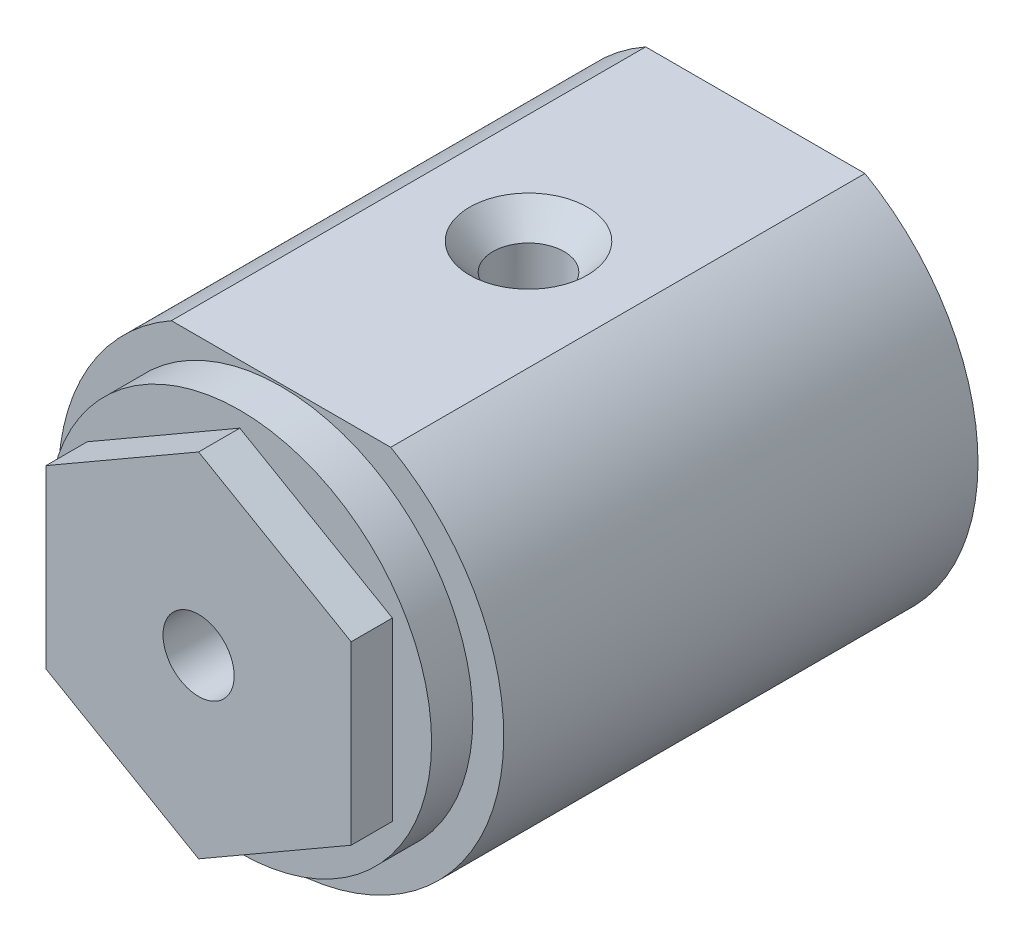
from build123d import *

# Parameters (mm, degrees)
BOSS_EXTRUDE1_DEPTH                            = 23
CSK_FOR_4_FLAT_HEAD_MACHINE_SCREW1_D           = 3.4544
CSK_FOR_4_FLAT_HEAD_MACHINE_SCREW1_DEPTH       = 3.5
CSK_FOR_4_FLAT_HEAD_MACHINE_SCREW1_CSINK_D     = 5.715
CSK_FOR_4_FLAT_HEAD_MACHINE_SCREW1_CSINK_ANGLE = 82
SKETCH5_R                                      = 9.3
BOSS_EXTRUDE2_DEPTH                            = 2
BOSS_EXTRUDE2_DEPTH_BACK                       = 4
BOSS_EXTRUDE3_DEPTH                            = 2
CUT_EXTRUDE1_DEPTH                             = 3.6
SKETCH8_R                                      = 1.725
CUT_EXTRUDE2_DEPTH                             = 9


with BuildPart() as part:
    # Base → Boss-Extrude1 (new body)
    with BuildSketch(Plane.XY):
        with BuildLine():
            Line((-5.31789432, 9.4), (5.31789432, 9.4))
            ThreePointArc((5.31789432, 9.4), (0, -10.8), (-5.31789432, 9.4))
        make_face()
        with BuildLine():
            Line((-5.253570215, 5.9), (5.253570215, 5.9))
            ThreePointArc((5.253570215, 5.9), (0, -7.9), (-5.253570215, 5.9))
        make_face(mode=Mode.SUBTRACT)
    extrude(amount=BOSS_EXTRUDE1_DEPTH)

    # CSK for #4 Flat Head Machine Screw1
    with Locations(Plane(origin=(0, 9.4, 0), x_dir=(1, 0, 0), z_dir=(0, 1, 0))):
        with Locations((0, -11)):
            CounterSinkHole(CSK_FOR_4_FLAT_HEAD_MACHINE_SCREW1_D / 2, CSK_FOR_4_FLAT_HEAD_MACHINE_SCREW1_CSINK_D / 2, depth=CSK_FOR_4_FLAT_HEAD_MACHINE_SCREW1_DEPTH, counter_sink_angle=CSK_FOR_4_FLAT_HEAD_MACHINE_SCREW1_CSINK_ANGLE)

    # Sketch5 → Boss-Extrude2 (add, two sides)
    with BuildSketch(Plane.XY.offset(23)) as boss_extrude2_sk:
        Circle(SKETCH5_R)
    extrude(amount=BOSS_EXTRUDE2_DEPTH)
    extrude(boss_extrude2_sk.sketch, amount=-BOSS_EXTRUDE2_DEPTH_BACK)

    # Sketch6 → Boss-Extrude3 (add)
    with BuildSketch(Plane.XY.offset(25)):
        Polygon((0, 8.544783984), (-7.4, 4.272391992), (-7.4, -4.272391992), (0, -8.544783984), (7.4, -4.272391992), (7.4, 4.272391992), align=None)
    extrude(amount=BOSS_EXTRUDE3_DEPTH)

    # Sketch7 → Cut-Extrude1 (cut)
    with BuildSketch(Plane(origin=(0, 0, 19), x_dir=(-1, 0, 0), z_dir=(0, 0, -1))):
        Polygon((0, 3.868246804), (-3.35, 1.934123402), (-3.35, -1.934123402), (0, -3.868246804), (3.35, -1.934123402), (3.35, 1.934123402), align=None)
    extrude(amount=-CUT_EXTRUDE1_DEPTH, mode=Mode.SUBTRACT)

    # Sketch8 → Cut-Extrude2 (cut, through all)
    with BuildSketch(Plane(origin=(0, 0, 19), x_dir=(-1, 0, 0), z_dir=(0, 0, -1))):
        Circle(SKETCH8_R)
    extrude(amount=-CUT_EXTRUDE2_DEPTH, mode=Mode.SUBTRACT)


solid = part.part
